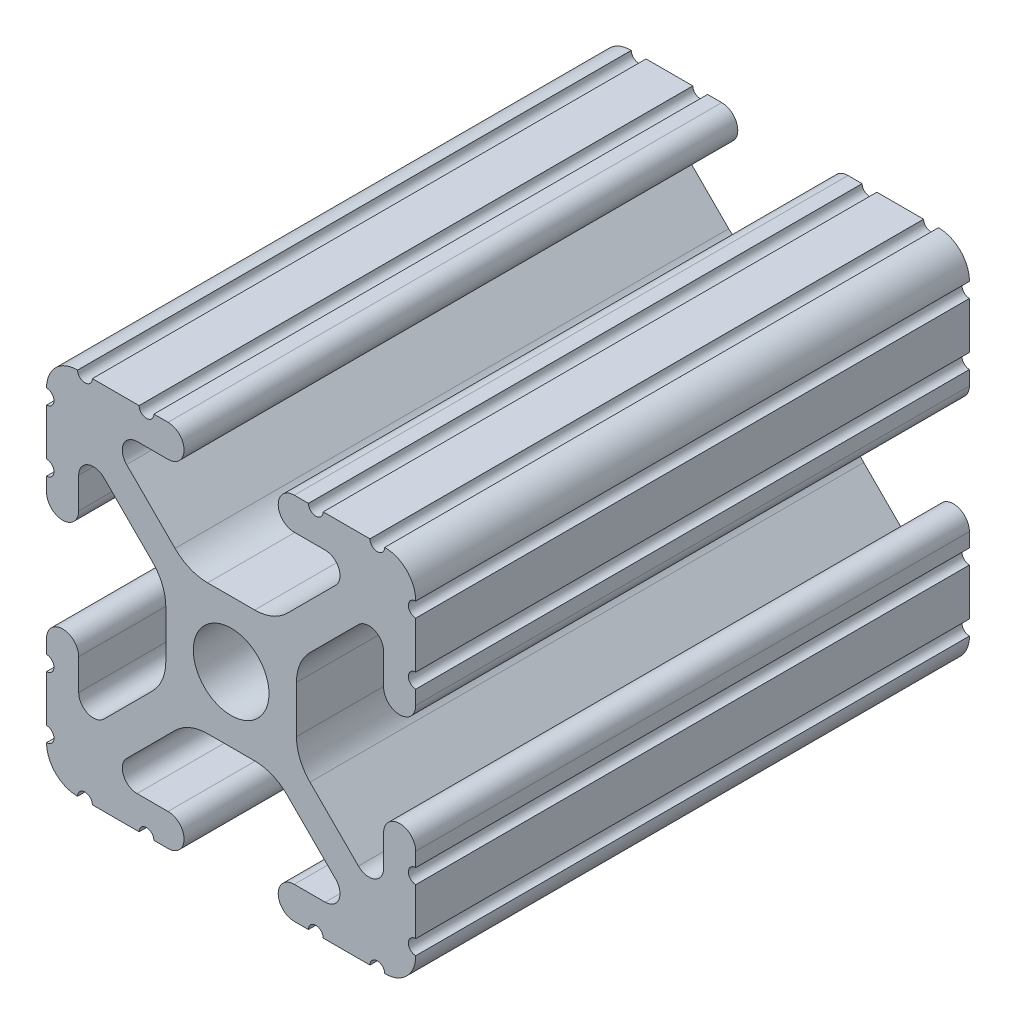
from build123d import *

# Parameters (mm, degrees)
SKETCH1_R           = 2.6035
BOSS_EXTRUDE1_DEPTH = 19.05


with BuildPart() as part:
    # Sketch1 → Boss-Extrude1 (new body, symmetric)
    with BuildSketch(Plane(origin=(0, 0, -450.85), x_dir=(-1, 0, 0), z_dir=(0, 0, -1))):
        with BuildLine():
            Line((12.7, -9.5504), (12.7, -6.3330836))
            ThreePointArc((12.7, -6.3330836), (12.192, -5.8250836), (12.7, -5.3170836))
            Line((12.7, -5.3170836), (12.7, -4.3434))
            ThreePointArc((12.7, -4.3434), (11.5951, -3.2385), (10.4902, -4.3434))
            Line((10.4902, -4.3434), (10.4902, -6.474794456))
            ThreePointArc((10.4902, -6.474794456), (9.863006367, -7.413456061), (8.75577951, -7.193214945))
            Line((8.75577951, -7.193214945), (5.42573597, -3.863171405))
            ThreePointArc((5.42573597, -3.863171405), (4.737482484, -2.833127272), (4.4958, -1.618107374))
            Line((4.4958, -1.618107374), (4.4958, 1.618107374))
            ThreePointArc((4.4958, 1.618107374), (4.737482484, 2.833127272), (5.42573597, 3.863171405))
            Line((5.42573597, 3.863171405), (8.75577951, 7.193214945))
            ThreePointArc((8.75577951, 7.193214945), (9.863006367, 7.413456061), (10.4902, 6.474794456))
            Line((10.4902, 6.474794456), (10.4902, 4.343399971))
            ThreePointArc((10.4902, 4.343399971), (11.5951, 3.238499971), (12.7, 4.343399971))
            Line((12.7, 4.343399971), (12.7, 5.3170836))
            ThreePointArc((12.7, 5.3170836), (12.192, 5.8250836), (12.7, 6.3330836))
            Line((12.7, 6.3330836), (12.7, 9.5504))
            ThreePointArc((12.7, 9.5504), (12.192000006, 10.058323491), (12.699846982, 10.566399977))
            ThreePointArc((12.699846982, 10.566399977), (12.082522516, 12.082522516), (10.566399977, 12.699846982))
            ThreePointArc((10.566399977, 12.699846982), (10.058323491, 12.192000006), (9.5504, 12.7))
            Line((9.5504, 12.7), (6.3330836, 12.7))
            ThreePointArc((6.3330836, 12.7), (5.8250836, 12.192), (5.3170836, 12.7))
            Line((5.3170836, 12.7), (4.3434, 12.7))
            ThreePointArc((4.3434, 12.7), (3.2385, 11.5951), (4.3434, 10.4902))
            Line((4.3434, 10.4902), (6.474794456, 10.4902))
            ThreePointArc((6.474794456, 10.4902), (7.413456061, 9.863006367), (7.193214945, 8.75577951))
            Line((7.193214945, 8.75577951), (3.863171405, 5.42573597))
            ThreePointArc((3.863171405, 5.42573597), (2.833127272, 4.737482484), (1.618107374, 4.4958))
            Line((1.618107374, 4.4958), (-1.618107374, 4.4958))
            ThreePointArc((-1.618107374, 4.4958), (-2.833127272, 4.737482484), (-3.863171405, 5.42573597))
            Line((-3.863171405, 5.42573597), (-7.193214945, 8.75577951))
            ThreePointArc((-7.193214945, 8.75577951), (-7.413456061, 9.863006367), (-6.474794456, 10.4902))
            Line((-6.474794456, 10.4902), (-4.343399971, 10.4902))
            ThreePointArc((-4.343399971, 10.4902), (-3.238499971, 11.5951), (-4.343399971, 12.7))
            Line((-4.343399971, 12.7), (-5.3170836, 12.7))
            ThreePointArc((-5.3170836, 12.7), (-5.8250836, 12.192), (-6.3330836, 12.7))
            Line((-6.3330836, 12.7), (-9.5504, 12.7))
            ThreePointArc((-9.5504, 12.7), (-10.058323491, 12.192000006), (-10.566399977, 12.699846982))
            ThreePointArc((-10.566399977, 12.699846982), (-12.082522516, 12.082522516), (-12.699846982, 10.566399977))
            ThreePointArc((-12.699846982, 10.566399977), (-12.192000006, 10.058323491), (-12.7, 9.5504))
            Line((-12.7, 9.5504), (-12.7, 6.3330836))
            ThreePointArc((-12.7, 6.3330836), (-12.192, 5.8250836), (-12.7, 5.3170836))
            Line((-12.7, 5.3170836), (-12.7, 4.3434))
            ThreePointArc((-12.7, 4.3434), (-11.5951, 3.2385), (-10.4902, 4.3434))
            Line((-10.4902, 4.3434), (-10.4902, 6.474794456))
            ThreePointArc((-10.4902, 6.474794456), (-9.863006367, 7.413456061), (-8.75577951, 7.193214945))
            Line((-8.75577951, 7.193214945), (-5.42573597, 3.863171405))
            ThreePointArc((-5.42573597, 3.863171405), (-4.737482484, 2.833127272), (-4.4958, 1.618107374))
            Line((-4.4958, 1.618107374), (-4.4958, -1.618107374))
            ThreePointArc((-4.4958, -1.618107374), (-4.737482484, -2.833127272), (-5.42573597, -3.863171405))
            Line((-5.42573597, -3.863171405), (-8.75577951, -7.193214945))
            ThreePointArc((-8.75577951, -7.193214945), (-9.863006367, -7.413456061), (-10.4902, -6.474794456))
            Line((-10.4902, -6.474794456), (-10.4902, -4.343399971))
            ThreePointArc((-10.4902, -4.343399971), (-11.5951, -3.238499971), (-12.7, -4.343399971))
            Line((-12.7, -4.343399971), (-12.7, -5.3170836))
            ThreePointArc((-12.7, -5.3170836), (-12.192, -5.8250836), (-12.7, -6.3330836))
            Line((-12.7, -6.3330836), (-12.7, -9.5504))
            ThreePointArc((-12.7, -9.5504), (-12.192000006, -10.058323491), (-12.699846982, -10.566399977))
            ThreePointArc((-12.699846982, -10.566399977), (-12.082522516, -12.082522516), (-10.566399977, -12.699846982))
            ThreePointArc((-10.566399977, -12.699846982), (-10.058323491, -12.192000006), (-9.5504, -12.7))
            Line((-9.5504, -12.7), (-6.3330836, -12.7))
            ThreePointArc((-6.3330836, -12.7), (-5.8250836, -12.192), (-5.3170836, -12.7))
            Line((-5.3170836, -12.7), (-4.3434, -12.7))
            ThreePointArc((-4.3434, -12.7), (-3.2385, -11.5951), (-4.3434, -10.4902))
            Line((-4.3434, -10.4902), (-6.474794456, -10.4902))
            ThreePointArc((-6.474794456, -10.4902), (-7.413456061, -9.863006367), (-7.193214945, -8.75577951))
            Line((-7.193214945, -8.75577951), (-3.863171405, -5.42573597))
            ThreePointArc((-3.863171405, -5.42573597), (-2.833127272, -4.737482484), (-1.618107374, -4.4958))
            Line((-1.618107374, -4.4958), (1.618107374, -4.4958))
            ThreePointArc((1.618107374, -4.4958), (2.833127272, -4.737482484), (3.863171405, -5.42573597))
            Line((3.863171405, -5.42573597), (7.193214945, -8.75577951))
            ThreePointArc((7.193214945, -8.75577951), (7.413456061, -9.863006367), (6.474794456, -10.4902))
            Line((6.474794456, -10.4902), (4.343399971, -10.4902))
            ThreePointArc((4.343399971, -10.4902), (3.238499971, -11.5951), (4.343399971, -12.7))
            Line((4.343399971, -12.7), (5.3170836, -12.7))
            ThreePointArc((5.3170836, -12.7), (5.8250836, -12.192), (6.3330836, -12.7))
            Line((6.3330836, -12.7), (9.5504, -12.7))
            ThreePointArc((9.5504, -12.7), (10.058323491, -12.192000006), (10.566399977, -12.699846982))
            ThreePointArc((10.566399977, -12.699846982), (12.082522516, -12.082522516), (12.699846982, -10.566399977))
            ThreePointArc((12.699846982, -10.566399977), (12.192000006, -10.058323491), (12.7, -9.5504))
        make_face()
        Circle(SKETCH1_R, mode=Mode.SUBTRACT)
    extrude(amount=BOSS_EXTRUDE1_DEPTH, both=True)


solid = part.part
